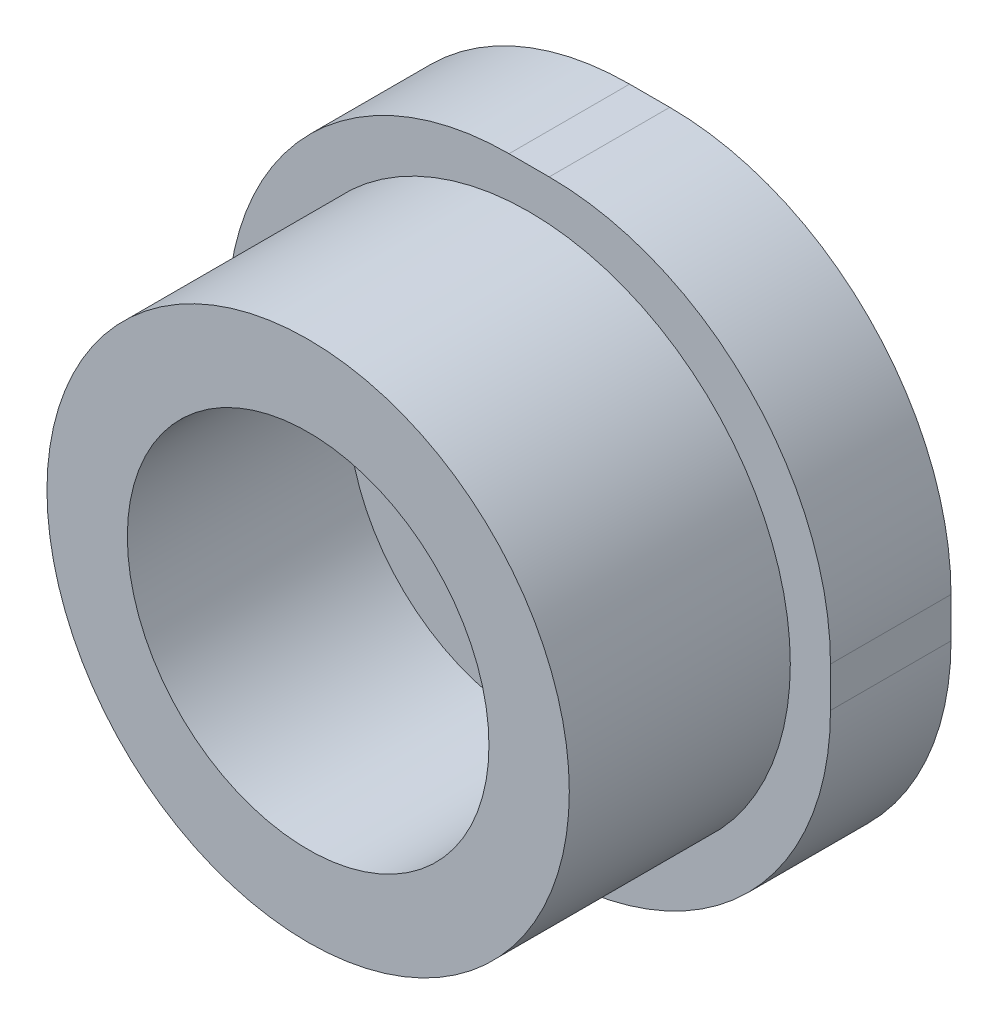
from build123d import *

# Parameters (mm, degrees)
SKETCH1_R           = 65
SKETCH1_R_2         = 45
BOSS_EXTRUDE1_DEPTH = 55
BOSS_EXTRUDE2_DEPTH = 30


with BuildPart() as part:
    # Sketch1 → Boss-Extrude1 (new body)
    with BuildSketch(Plane.XY):
        Circle(SKETCH1_R)
        Circle(SKETCH1_R_2, mode=Mode.SUBTRACT)
    extrude(amount=BOSS_EXTRUDE1_DEPTH)

    # Sketch2 → Boss-Extrude2 (add)
    with BuildSketch(Plane(origin=(0, 0, 0), x_dir=(-1, 0, 0), z_dir=(0, 0, -1))):
        with BuildLine():
            Line((-5, -75), (5, -75))
            ThreePointArc((5, -75), (54.497474683, -54.497474683), (75, -5))
            Line((75, -5), (75, 5))
            ThreePointArc((75, 5), (54.497474683, 54.497474683), (5, 75))
            Line((5, 75), (-5, 75))
            ThreePointArc((-5, 75), (-54.497474683, 54.497474683), (-75, 5))
            Line((-75, 5), (-75, -5))
            ThreePointArc((-75, -5), (-54.497474683, -54.497474683), (-5, -75))
        make_face()
    extrude(amount=BOSS_EXTRUDE2_DEPTH)


solid = part.part
